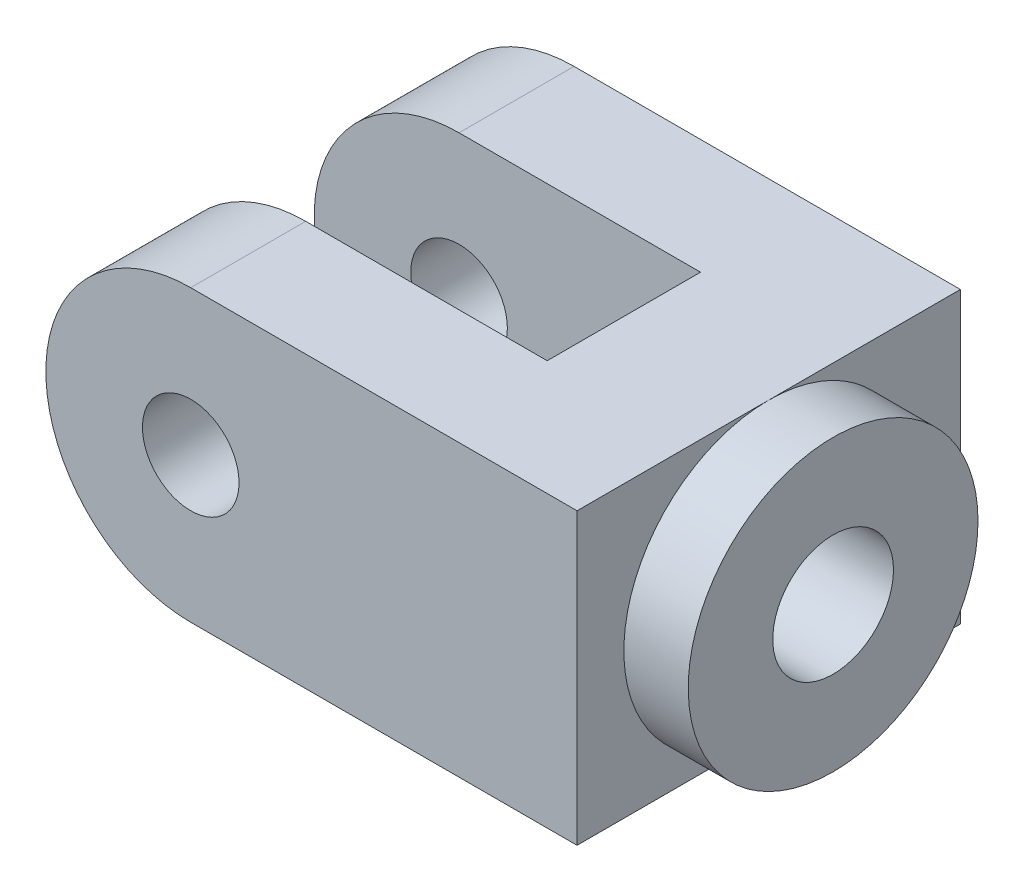
from build123d import *

# Parameters (mm, degrees)
SKETCH1_W               = 132
SKETCH1_H               = 72
BOSS_EXTRUDE1_DEPTH     = 47.625
CUT_EXTRUDE1_DEPTH      = 1
CUT_EXTRUDE1_DEPTH_BACK = 96.25
SKETCH3_W               = 96
SKETCH3_H               = 38.1
CUT_EXTRUDE2_DEPTH      = 73
SKETCH4_R               = 15
CUT_EXTRUDE3_DEPTH      = 133
SKETCH5_R               = 36
SKETCH5_R_2             = 15
BOSS_EXTRUDE2_DEPTH     = 16
SKETCH6_R               = 12
CUT_EXTRUDE4_DEPTH      = 96.25


with BuildPart() as part:
    # Sketch1 → Boss-Extrude1 (new body, symmetric)
    with BuildSketch(Plane.XY):
        Rectangle(SKETCH1_W, SKETCH1_H)
    extrude(amount=BOSS_EXTRUDE1_DEPTH, both=True)

    # Sketch2 → Cut-Extrude1 (cut, two sides)
    with BuildSketch(Plane.XY.offset(47.625)) as cut_extrude1_sk:
        with BuildLine():
            Line((220.000004886, 36), (-30, 36))
            ThreePointArc((-30, 36), (-66, 1.527e-06), (-30.000003054, -36))
            Line((-30.000003054, -36), (220.000001832, -36.000021206))
            Line((220.000001832, -36.000021206), (-280.000007939, -36))
            Line((-280.000007939, -36), (-280.000004886, 36.000021206))
            Line((-280.000004886, 36.000021206), (220.000004886, 36))
        make_face()
    extrude(amount=CUT_EXTRUDE1_DEPTH, mode=Mode.SUBTRACT)
    extrude(cut_extrude1_sk.sketch, amount=-CUT_EXTRUDE1_DEPTH_BACK, mode=Mode.SUBTRACT)

    # Sketch3 → Cut-Extrude2 (cut, through all)
    with BuildSketch(Plane(origin=(0, 36, 0), x_dir=(1, 0, 0), z_dir=(0, 1, 0))):
        with Locations((-18, 0)):
            Rectangle(SKETCH3_W, SKETCH3_H)
    extrude(amount=-CUT_EXTRUDE2_DEPTH, mode=Mode.SUBTRACT)

    # Sketch4 → Cut-Extrude3 (cut, through all)
    with BuildSketch(Plane(origin=(66, 0, 0), x_dir=(0, 0, -1), z_dir=(1, 0, 0))):
        Circle(SKETCH4_R)
    extrude(amount=-CUT_EXTRUDE3_DEPTH, mode=Mode.SUBTRACT)

    # Sketch5 → Boss-Extrude2 (add)
    with BuildSketch(Plane(origin=(66, 0, 0), x_dir=(0, 0, -1), z_dir=(1, 0, 0))):
        Circle(SKETCH5_R)
        Circle(SKETCH5_R_2, mode=Mode.SUBTRACT)
    extrude(amount=BOSS_EXTRUDE2_DEPTH)

    # Sketch6 → Cut-Extrude4 (cut, through all)
    with BuildSketch(Plane.XY.offset(47.625)):
        with Locations((-30, 0)):
            Circle(SKETCH6_R)
    extrude(amount=-CUT_EXTRUDE4_DEPTH, mode=Mode.SUBTRACT)


solid = part.part
